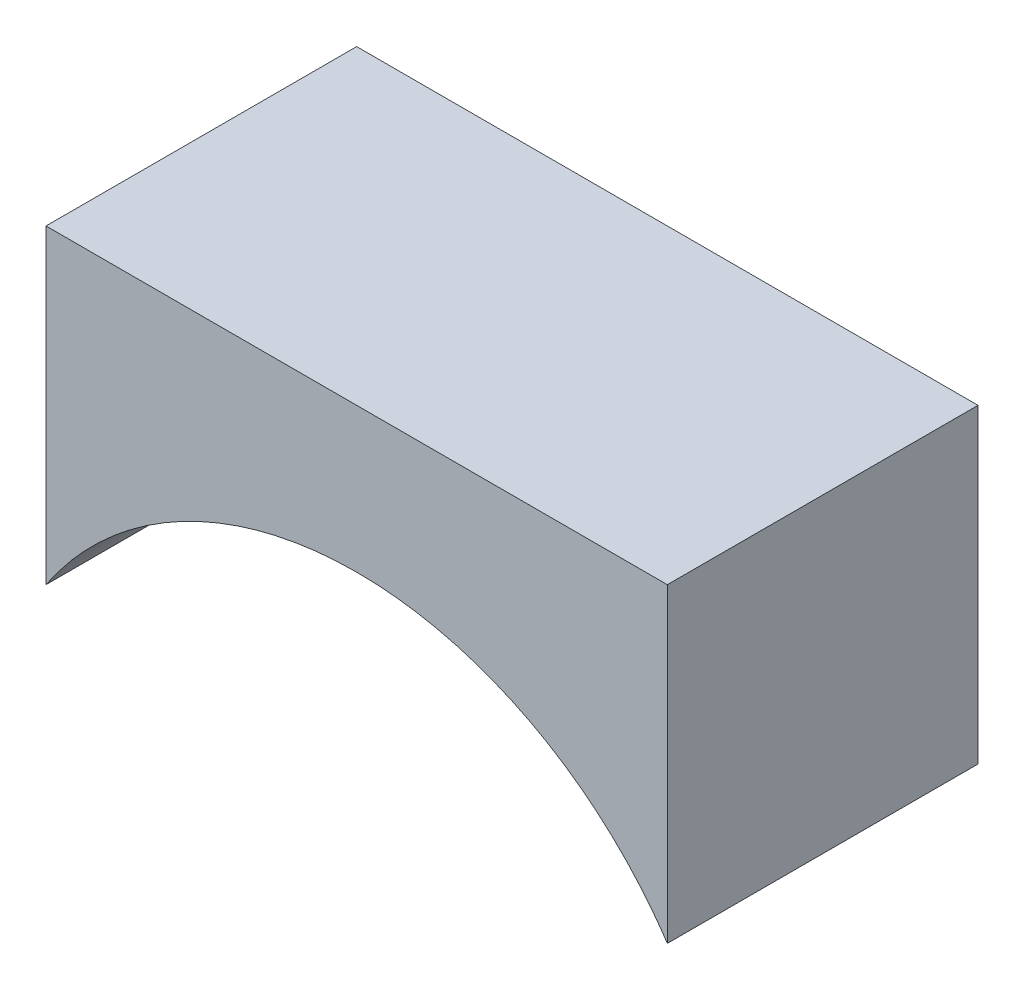
from build123d import *

# Parameters (mm, degrees)
BOSS_EXTRUDE1_DEPTH = 150


with BuildPart() as part:
    # Sketch1 → Boss-Extrude1 (new body)
    with BuildSketch(Plane.XY):
        with BuildLine():
            Line((1400.130465677, -323.279128227), (1400.130465677, -173.279128227))
            Line((1400.130465677, -173.279128227), (1700.130465677, -173.279128227))
            Line((1700.130465677, -173.279128227), (1700.130465677, -323.279128227))
            add(Edge.make_bspline(
                [(1700.130465677, -323.279128227), (1698.317438948, -320.562056975), (1689.612910417, -308.254282783), (1671.385962605, -288.332192119), (1642.70909627, -267.271370209), (1610.474485353, -252.209805174), (1575.920887874, -243.726304512), (1540.376179204, -242.146884395), (1505.206322566, -247.532241053), (1471.762875826, -259.675418249), (1441.331051887, -278.109760495), (1417.451149151, -299.957755682), (1404.907473934, -316.121897264), (1400.130465677, -323.279128227)],
                knots=[2.301855219, 2.301855219, 2.301855219, 2.301855219, 2.35619449, 2.552544031, 2.748893572, 2.945243113, 3.141592654, 3.337942194, 3.534291735, 3.730641276, 3.926990817, 4.123340358, 4.266490277, 4.266490277, 4.266490277, 4.266490277], degree=3))
        make_face()
    extrude(amount=-BOSS_EXTRUDE1_DEPTH)


solid = part.part
